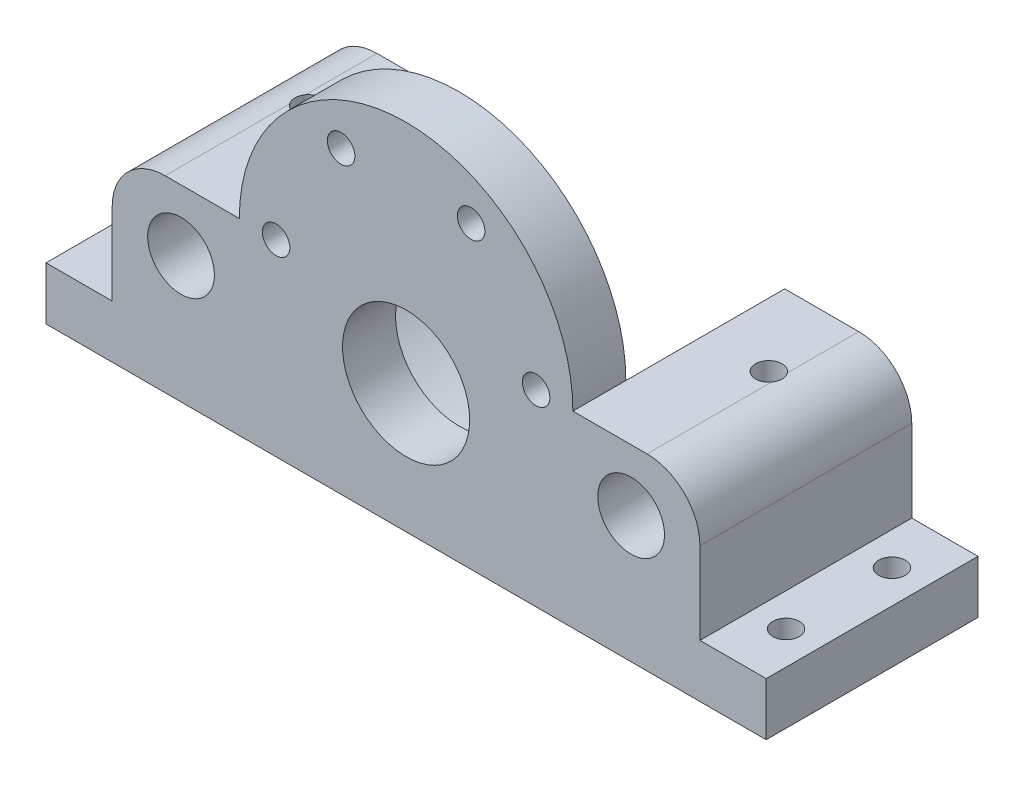
from build123d import *

# Parameters (mm, degrees)
SKETCH1_W               = 86.36
SKETCH1_H               = 6.35
BOSS_EXTRUDE1_DEPTH     = 25.4
BOSS_EXTRUDE2_DEPTH     = 25.4
SKETCH3_R               = 7.62
SKETCH3_R_2             = 1.651
CUT_EXTRUDE3_DEPTH      = 25.4
SKETCH4_R               = 20
CUT_EXTRUDE4_DEPTH      = 19.05
SKETCH6_W               = 40
SKETCH6_H               = 10.16
CUT_EXTRUDE6_DEPTH      = 19.05
BOSS_EXTRUDE3_START     = -25.4
SKETCH7_W               = 15.24
SKETCH7_H               = 16.19
SKETCH7_R               = 4
BOSS_EXTRUDE3_DEPTH     = 25.4
FILLET1_R               = 6.35
SKETCH9_R               = 1.5875
CUT_EXTRUDE7_DEPTH      = 62.801201445
CUT_EXTRUDE8_REACH      = 56.934
CUT_EXTRUDE8_END_RADIUS = 4
SKETCH11_R              = 1.5875


with BuildPart() as part:
    # Sketch1 → Boss-Extrude1 (new body)
    with BuildSketch(Plane.XY):
        Rectangle(SKETCH1_W, SKETCH1_H)
    extrude(amount=BOSS_EXTRUDE1_DEPTH)

    # Sketch2 → Boss-Extrude2 (add)
    with BuildSketch(Plane.XY.offset(25.4)):
        with BuildLine():
            ThreePointArc((20, 19.365), (0, 39.365), (-20, 19.365))
            ThreePointArc((-20, 19.365), (-17.816396252, 10.277864885), (-11.742397541, 3.175))
            Line((-11.742397541, 3.175), (11.742397541, 3.175))
            ThreePointArc((11.742397541, 3.175), (17.816396252, 10.277864885), (20, 19.365))
        make_face()
        with BuildLine():
            Line((11.742397541, 3.175), (-11.742397541, 3.175))
            ThreePointArc((-11.742397541, 3.175), (0, -0.635), (11.742397541, 3.175))
        make_face()
        with BuildLine():
            ThreePointArc((-11.742397541, 3.175), (-17.816396252, 10.277864885), (-20, 19.365))
            Line((-20, 19.365), (-20, 3.175))
            Line((-20, 3.175), (-11.742397541, 3.175))
        make_face()
        with BuildLine():
            Line((20, 3.175), (20, 19.365))
            ThreePointArc((20, 19.365), (17.816396252, 10.277864885), (11.742397541, 3.175))
            Line((11.742397541, 3.175), (20, 3.175))
        make_face()
    extrude(amount=-BOSS_EXTRUDE2_DEPTH)

    # Sketch3 → Cut-Extrude3 (cut)
    with BuildSketch(Plane.XY.offset(25.4)):
        with Locations((0, 12.253)):
            Circle(SKETCH3_R)
        with Locations((-7.79423, 32.755818299)):
            Circle(SKETCH3_R_2)
        with Locations((7.79423, 32.755818299)):
            Circle(SKETCH3_R_2)
        with Locations((-15.58846, 19.365)):
            Circle(SKETCH3_R_2)
        with Locations((15.58846, 19.365)):
            Circle(SKETCH3_R_2)
    extrude(amount=-CUT_EXTRUDE3_DEPTH, mode=Mode.SUBTRACT)

    # Sketch4 → Cut-Extrude4 (cut)
    with BuildSketch(Plane(origin=(0, 0, 0), x_dir=(-1, 0, 0), z_dir=(0, 0, -1))):
        with Locations((0, 19.365)):
            Circle(SKETCH4_R)
    extrude(amount=-CUT_EXTRUDE4_DEPTH, mode=Mode.SUBTRACT)

    # Sketch6 → Cut-Extrude6 (cut)
    with BuildSketch(Plane(origin=(0, 0, 0), x_dir=(-1, 0, 0), z_dir=(0, 0, -1))):
        with Locations((0, 14.285)):
            Rectangle(SKETCH6_W, SKETCH6_H)
    extrude(amount=-CUT_EXTRUDE6_DEPTH, mode=Mode.SUBTRACT)

    # Sketch7 → Boss-Extrude3 (add)
    with BuildSketch(Plane.XY.offset(25.4).offset(BOSS_EXTRUDE3_START)):
        with Locations((-27.62, 11.27)):
            Rectangle(SKETCH7_W, SKETCH7_H)
        with Locations((-26.9875, 11.999)):
            Circle(SKETCH7_R, mode=Mode.SUBTRACT)
    boss_extrude3 = extrude(amount=BOSS_EXTRUDE3_DEPTH)

    # Mirror2: Boss-Extrude3 across plane
    add(boss_extrude3.mirror(Plane(origin=(0, 0, 0), x_dir=(0, 0, 1), z_dir=(1, 0, 0))))

    # Fillet1
    fillet1_edges = [part.edges().sort_by_distance(p)[0] for p in [
        (-35.24, 19.365, 12.7),
        (35.24, 19.365, 12.7),
    ]]
    fillet(fillet1_edges, radius=FILLET1_R)

    # Sketch9 → Cut-Extrude7 (cut, through all)
    with BuildSketch(Plane(origin=(0, 3.175, 0), x_dir=(1, 0, 0), z_dir=(0, 1, 0))):
        with Locations(Location((-39.21, -6.35, 0), (0, 0, 180))):
            Circle(SKETCH9_R)
        with Locations(Location((-39.21, -19.05, 0), (0, 0, 180))):
            Circle(SKETCH9_R)
    cut_extrude7 = extrude(amount=-CUT_EXTRUDE7_DEPTH, mode=Mode.SUBTRACT)

    # Mirror3: Cut-Extrude7 across plane
    add(cut_extrude7.mirror(Plane(origin=(0, 0, 0), x_dir=(0, 0, 1), z_dir=(1, 0, 0))), mode=Mode.SUBTRACT)

    # Cut-Extrude8: up to this cylinder (the profile starts outside it)
    cut_extrude8_end = Plane(origin=(-26.9875, 11.999, 9.525), z_dir=(0, 0, 1)) * Cylinder(CUT_EXTRUDE8_END_RADIUS, 122.868, mode=Mode.PRIVATE)
    # Sketch11 → Cut-Extrude8 (cut, up to the surface)
    with BuildSketch(Plane(origin=(0, 19.365, 0), x_dir=(1, 0, 0), z_dir=(0, 1, 0)), mode=Mode.PRIVATE) as cut_extrude8_sk1:
        with Locations(Location((-27.62, -9.525, 0), (0, 0, 270))):
            Circle(SKETCH11_R)
    cut_extrude8_tool1 = extrude(cut_extrude8_sk1.sketch, amount=-CUT_EXTRUDE8_REACH, mode=Mode.PRIVATE) - cut_extrude8_end
    cut_extrude8 = cut_extrude8_tool1.solids().sort_by_distance((-27.62, 19.365, 9.525))[0]
    add(cut_extrude8, mode=Mode.SUBTRACT)

    # Mirror4: Cut-Extrude8 across plane
    add(cut_extrude8.mirror(Plane(origin=(0, 0, 0), x_dir=(0, 0, 1), z_dir=(1, 0, 0))), mode=Mode.SUBTRACT)


solid = part.part
